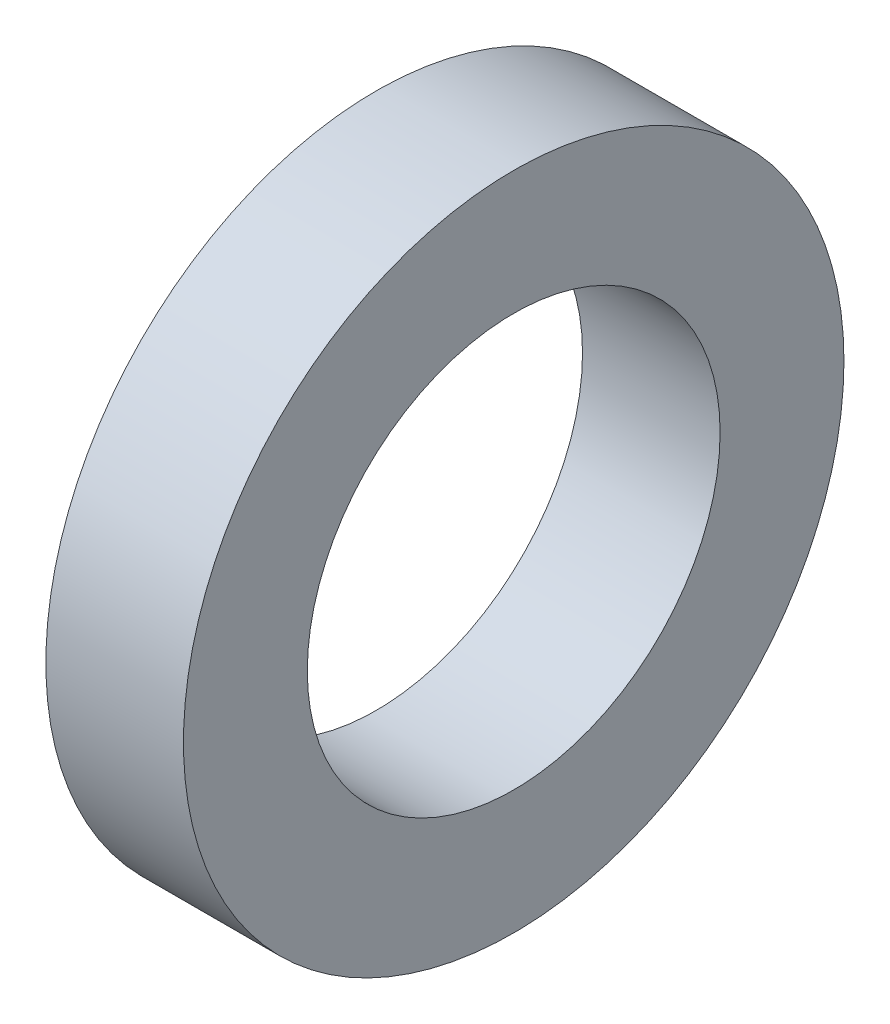
from build123d import *

# Parameters (mm, degrees)
SKETCH_1_R      = 12
SKETCH_1_R_2    = 7.5
EXTRUDE_1_DEPTH = 5


with BuildPart() as part:
    # Эскиз1 → Бобышка-Вытянуть1 (new body)
    with BuildSketch(Plane(origin=(0, 0, 0), x_dir=(0, 0, -1), z_dir=(1, 0, 0))):
        Circle(SKETCH_1_R)
        Circle(SKETCH_1_R_2, mode=Mode.SUBTRACT)
    extrude(amount=EXTRUDE_1_DEPTH)


solid = part.part
